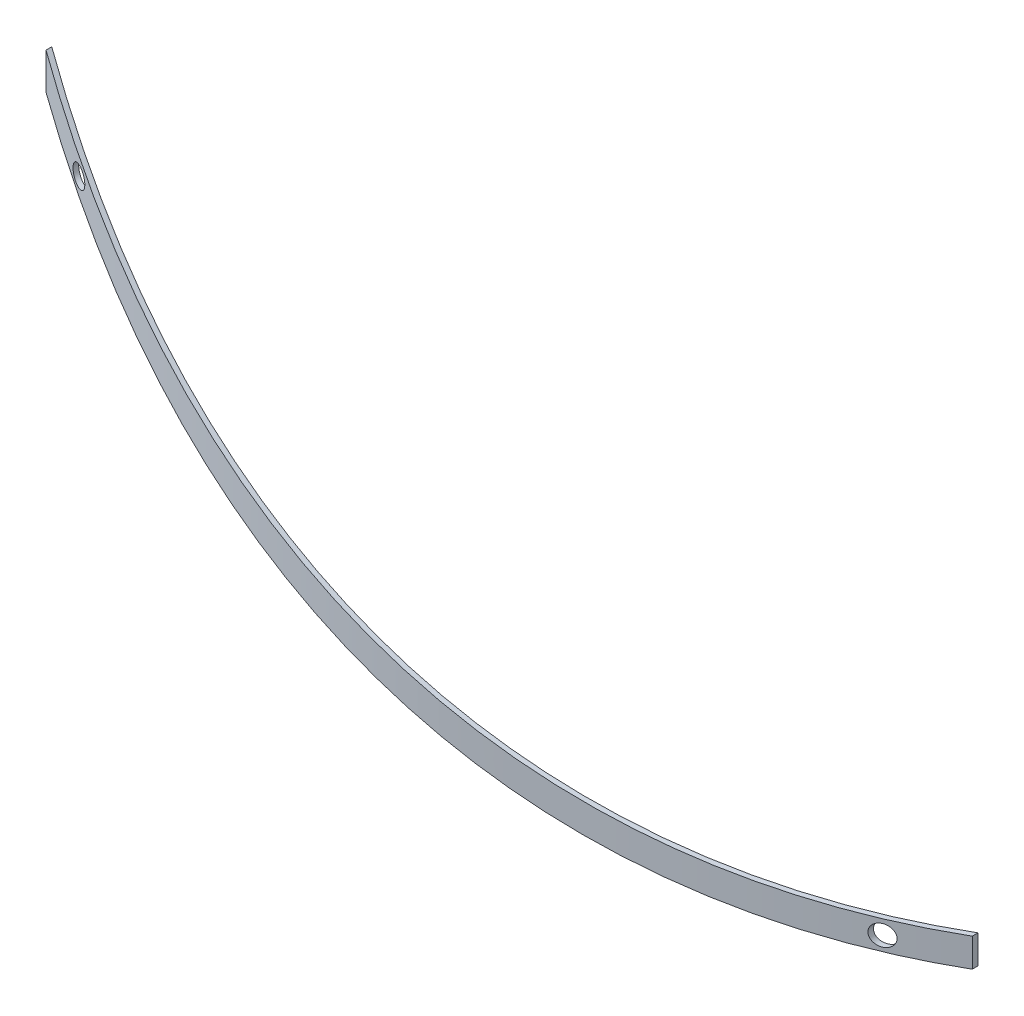
from build123d import *

# Parameters (mm, degrees)
BOSS_EXTRUDE1_DEPTH = 3000
SKETCH3_OUTSIDE_W   = 5624.574
SKETCH3_OUTSIDE_H   = 4094.574
SKETCH3_OUTSIDE_R   = 50
CUT_EXTRUDE1_DEPTH  = 3000


with BuildPart() as part:
    # Sketch2 → Boss-Extrude1 (new body)
    with BuildSketch(Plane(origin=(0, 0, 0), x_dir=(1, 0, 0), z_dir=(0, 1, 0))):
        with BuildLine():
            Line((3714.57215032, -2111.76142974), (3714.57215032, -2139.785736105))
            ThreePointArc((3714.57215032, -2139.785736105), (1449.57215032, -2679.208850129), (-815.42784968, -2139.785736105))
            Line((-815.42784968, -2139.785736105), (-815.42784968, -2111.76142974))
            ThreePointArc((-815.42784968, -2111.76142974), (1449.57215032, -2654.208850129), (3714.57215032, -2111.76142974))
        make_face()
    extrude(amount=BOSS_EXTRUDE1_DEPTH)

    # Sketch3 outside → Cut-Extrude1 (cut)
    with BuildSketch(Plane.XY):
        with Locations((1449.572, 1500)):
            Rectangle(SKETCH3_OUTSIDE_W, SKETCH3_OUTSIDE_H)
        with BuildLine():
            Line((-815.42784968, 2495.906119987), (-815.42784968, 2674.67299459))
            ThreePointArc((-815.42784968, 2674.67299459), (1313.444712633, 1516.260061816), (3714.57215032, 1186.705912429))
            Line((3714.57215032, 1186.705912429), (3714.57215032, 1046.569571941))
            ThreePointArc((3714.57215032, 1046.569571941), (1320.206110828, 1366.895486913), (-815.42784968, 2495.906119987))
        make_face(mode=Mode.SUBTRACT)
        with Locations((-515.42784968, 2360.019053002)):
            Circle(SKETCH3_OUTSIDE_R)
        with Locations((3414.57215032, 1110.019053002)):
            Circle(SKETCH3_OUTSIDE_R)
    extrude(amount=CUT_EXTRUDE1_DEPTH, mode=Mode.SUBTRACT)


solid = part.part
